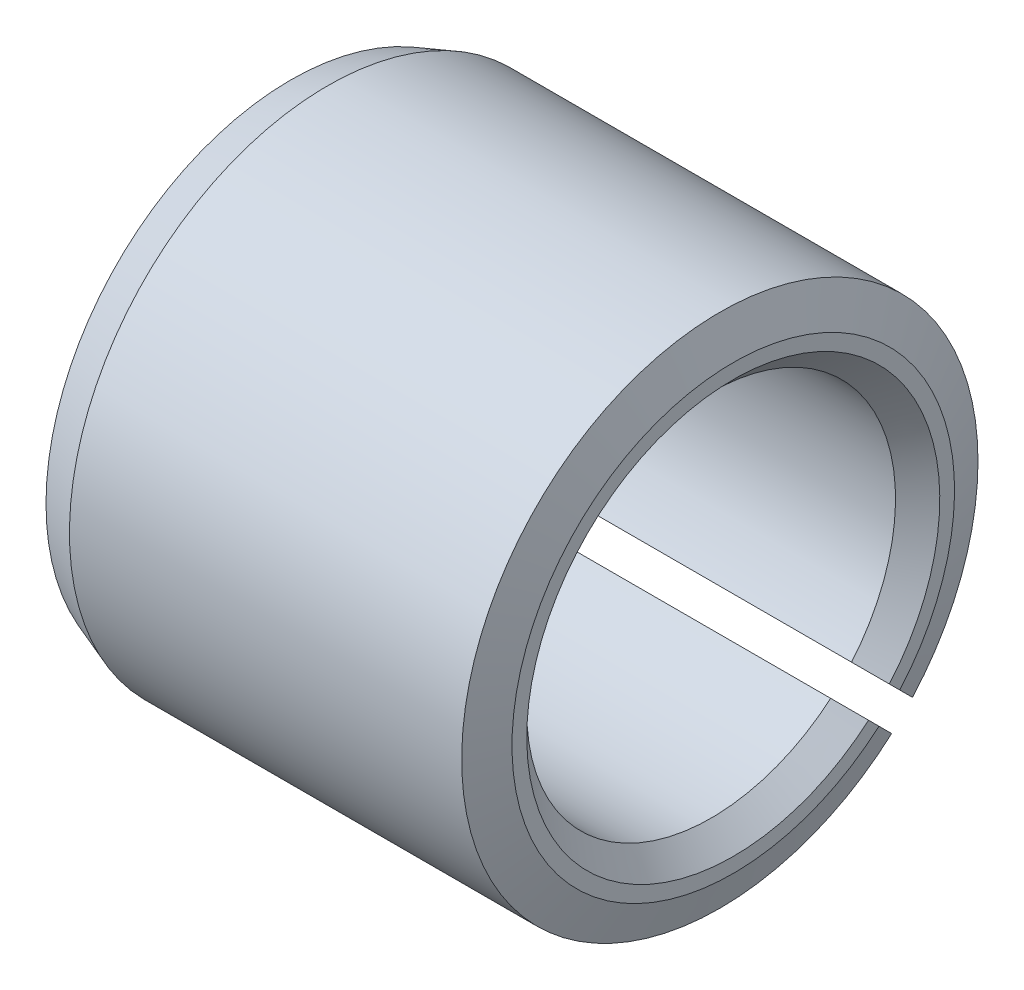
from build123d import *

# Parameters (mm, degrees)
SKETCH1_W             = 6
SKETCH1_H             = 3.5
CUT_EXTRUDE1_DEPTH    = 7
SKETCH3_W             = 6
SKETCH3_H             = 2.5
CHAMFER1_SIZE         = 0.3
CHAMFER2_SIZE         = 0.181985117
CHAMFER2_SIZE2        = 0.5
CHAMFER2_PART_2_SIZE  = 0.181985117
CHAMFER2_PART_2_SIZE2 = 0.5


with BuildPart() as part:
    # Sketch1 → Revolve1 (revolve)
    with BuildSketch(Plane.XY):
        with Locations((3, 1.75)):
            Rectangle(SKETCH1_W, SKETCH1_H)
    revolve(axis=Axis((0, 0, 0), (1, 0, 0)))

    # Sketch2 → Cut-Extrude1 (cut, through all)
    with BuildSketch(Plane.ZY):
        with BuildLine():
            Line((-2.329408464, -2.612251176), (-1.620679662, -1.903522375))
            ThreePointArc((-1.620679662, -1.903522375), (-1.767766953, -1.767766953), (-1.903522375, -1.620679662))
            Line((-1.903522375, -1.620679662), (-2.612251176, -2.329408464))
            ThreePointArc((-2.612251176, -2.329408464), (-2.474873734, -2.474873734), (-2.329408464, -2.612251176))
        make_face()
    extrude(amount=-CUT_EXTRUDE1_DEPTH, mode=Mode.SUBTRACT)

    # Sketch3 → Cut-Revolve1 (revolve, cut)
    with BuildSketch(Plane.XY):
        with Locations((3, 1.25)):
            Rectangle(SKETCH3_W, SKETCH3_H)
    revolve(axis=Axis((0, 0, 0), (1, 0, 0)), mode=Mode.SUBTRACT)

    # Chamfer1
    chamfer1_edges = [part.edges().sort_by_distance(p)[0] for p in [
        (0, -0.863479607, 2.346146408),
        (6, -0.863479607, 2.346146408),
    ]]
    chamfer(chamfer1_edges, length=CHAMFER1_SIZE)

    # Chamfer2
    chamfer2_edges = [part.edges().sort_by_distance(p)[0] for p in [
        (0, -1.246419047, 3.270541172),
    ]]
    chamfer2_side = [part.faces().sort_by_distance(p)[0] for p in [
        (0, -2.011414437, -2.434257149),
    ]]
    chamfer(chamfer2_edges, length=CHAMFER2_SIZE, length2=CHAMFER2_SIZE2, reference=chamfer2_side[0])

    # Chamfer2 part 2
    chamfer2_part_2_edges = [part.edges().sort_by_distance(p)[0] for p in [
        (6, -1.246419047, 3.270541172),
    ]]
    chamfer2_part_2_side = [part.faces().sort_by_distance(p)[0] for p in [
        (3, -1.246419047, 3.270541172),
    ]]
    chamfer(chamfer2_part_2_edges, length=CHAMFER2_PART_2_SIZE, length2=CHAMFER2_PART_2_SIZE2, reference=chamfer2_part_2_side[0])


solid = part.part
